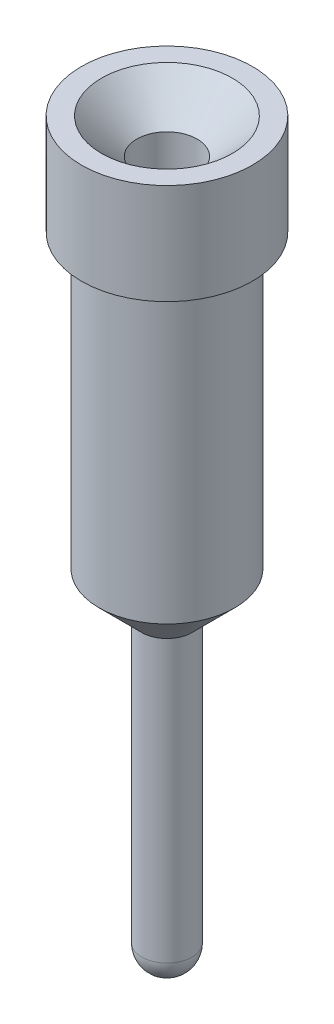
from build123d import *


with BuildPart() as part:
    # Sketch1 → Revolve1 (revolve)
    with BuildSketch(Plane.XY, mode=Mode.PRIVATE) as revolve1_sk:
        with BuildLine():
            Line((-0.85, 0), (-0.85, -1))
            Line((-0.85, -1), (-0.675, -1))
            Line((-0.675, -1), (-0.675, -3.9))
            Line((-0.675, -3.9), (-0.25, -4.325))
            Line((-0.25, -4.325), (-0.25, -7.12))
            ThreePointArc((-0.25, -7.12), (-0.176776695, -7.296776695), (0, -7.37))
            Line((0, -7.37), (0, -4))
            Line((0, -4), (-0.3, -3.7))
            Line((-0.3, -3.7), (-0.3, -0.35))
            Line((-0.3, -0.35), (-0.65, 0))
            Line((-0.65, 0), (-0.85, 0))
        make_face()
    revolve(revolve1_sk.sketch.rotate(Axis((0, 28.992562867, 0), (0, -1, 0)), 270), axis=Axis((0, 28.992562867, 0), (0, -1, 0)))  # turned: the seam where the file's is


solid = part.part
